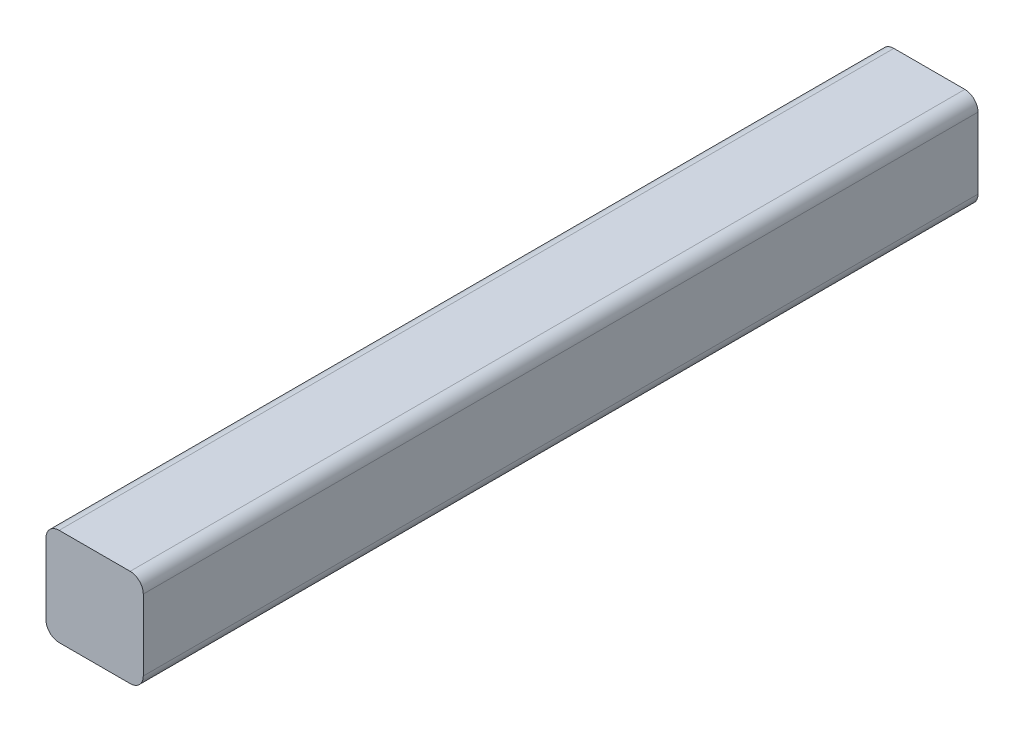
from build123d import *

# Parameters (mm, degrees)
SKETCH1_W           = 14.8
SKETCH1_H           = 14.8
BOSS_EXTRUDE1_DEPTH = 127
FILLET1_R           = 2


with BuildPart() as part:
    # Sketch1 → Boss-Extrude1 (new body)
    with BuildSketch(Plane.XY):
        Rectangle(SKETCH1_W, SKETCH1_H)
    extrude(amount=BOSS_EXTRUDE1_DEPTH)

    # Fillet1
    fillet1_edges = [part.edges().sort_by_distance(p)[0] for p in [
        (-7.4, 7.4, 63.5),
        (7.4, 7.4, 63.5),
        (7.4, -7.4, 63.5),
        (-7.4, -7.4, 63.5),
    ]]
    fillet(fillet1_edges, radius=FILLET1_R)


solid = part.part
